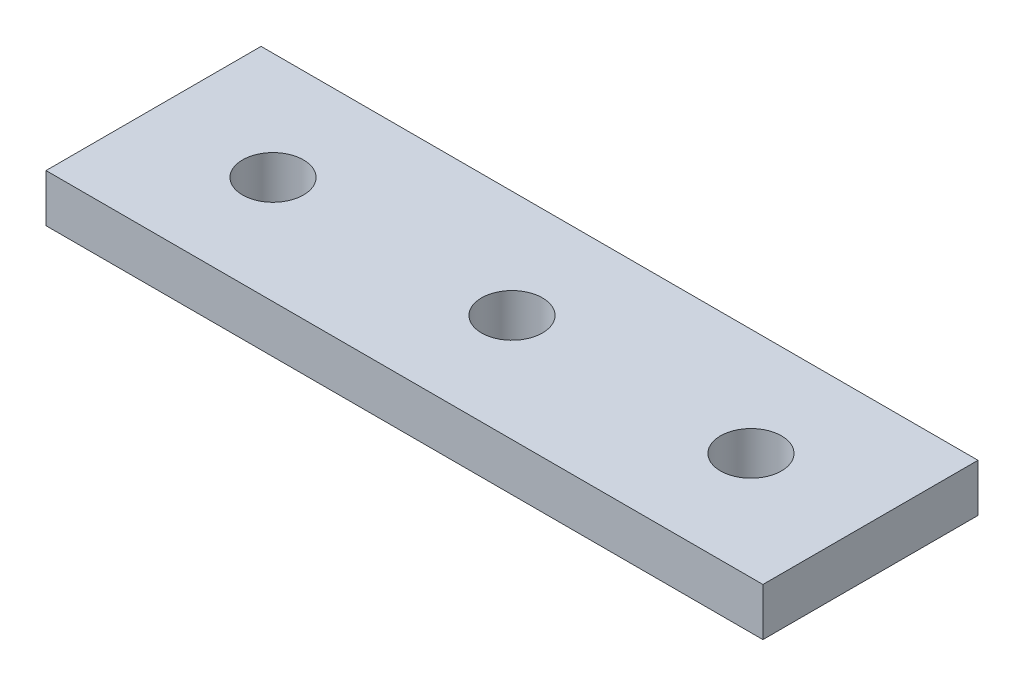
from build123d import *

# Parameters (mm, degrees)
SKETCH1_W           = 60
SKETCH1_H           = 18
SKETCH1_R           = 2.55
BOSS_EXTRUDE1_DEPTH = 4


with BuildPart() as part:
    # Sketch1 → Boss-Extrude1 (new body)
    with BuildSketch(Plane(origin=(0, 0, 0), x_dir=(1, 0, 0), z_dir=(0, 1, 0))):
        Rectangle(SKETCH1_W, SKETCH1_H)
        with Locations((-20, 0)):
            Circle(SKETCH1_R, mode=Mode.SUBTRACT)
        with Locations((20, 0)):
            Circle(SKETCH1_R, mode=Mode.SUBTRACT)
        Circle(SKETCH1_R, mode=Mode.SUBTRACT)
    extrude(amount=BOSS_EXTRUDE1_DEPTH)


solid = part.part
